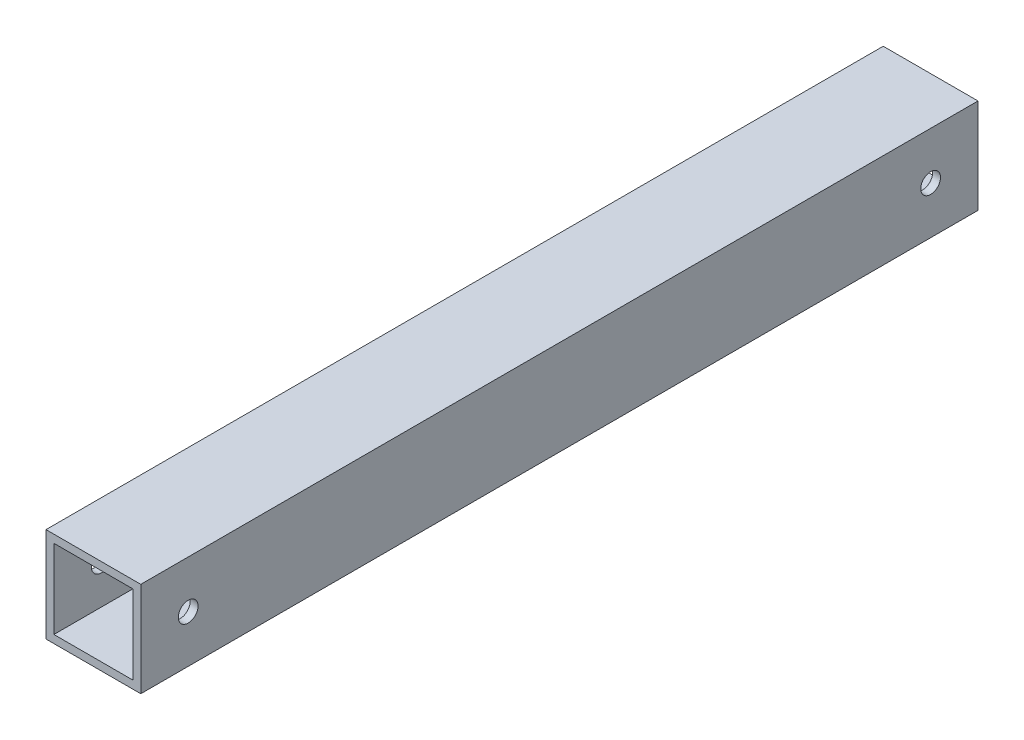
from build123d import *

# Parameters (mm, degrees)
SKETCH1_W           = 76.2
SKETCH1_H           = 76.2
SKETCH1_W_2         = 63.5
SKETCH1_H_2         = 63.5
BOSS_EXTRUDE1_DEPTH = 336.55
SKETCH2_R           = 7.9375
CUT_EXTRUDE1_DEPTH  = 77.2


with BuildPart() as part:
    # Sketch1 → Boss-Extrude1 (new body, symmetric)
    with BuildSketch(Plane.XY):
        Rectangle(SKETCH1_W, SKETCH1_H)
        Rectangle(SKETCH1_W_2, SKETCH1_H_2, mode=Mode.SUBTRACT)
    extrude(amount=BOSS_EXTRUDE1_DEPTH, both=True)

    # Sketch2 → Cut-Extrude1 (cut, through all)
    with BuildSketch(Plane(origin=(38.1, 0, 0), x_dir=(0, 0, -1), z_dir=(1, 0, 0))):
        with Locations((298.45, 0)):
            Circle(SKETCH2_R)
    cut_extrude1 = extrude(amount=-CUT_EXTRUDE1_DEPTH, mode=Mode.SUBTRACT)

    # Mirror1: Cut-Extrude1 across plane
    add(cut_extrude1.mirror(Plane.XY), mode=Mode.SUBTRACT)


solid = part.part
